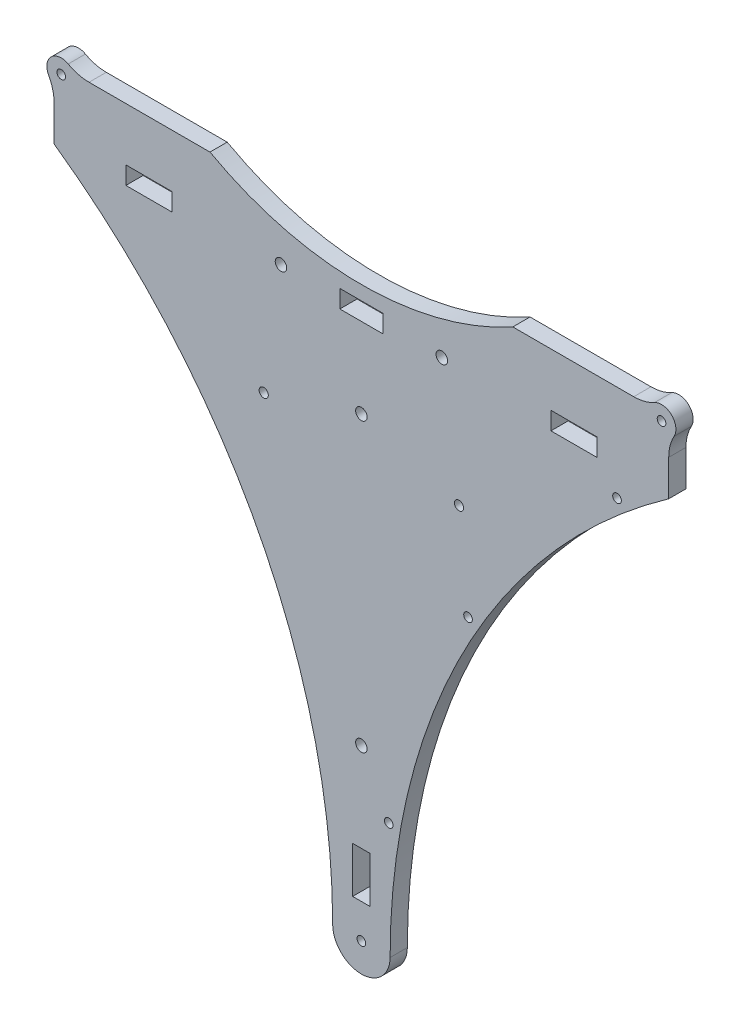
from build123d import *

# Parameters (mm, degrees)
SKETCH1_R           = 1.5
SKETCH1_R_2         = 2
SKETCH1_R_3         = 1.6
SKETCH1_W           = 16
SKETCH1_H           = 6.2
SKETCH1_W_2         = 6.1
SKETCH1_H_2         = 16
SKETCH1_W_3         = 15
BOSS_EXTRUDE1_DEPTH = 6
SKETCH2_R           = 1.5
CUT_EXTRUDE1_DEPTH  = 7


with BuildPart() as part:
    # Sketch1 → Boss-Extrude1 (new body)
    with BuildSketch(Plane.XY):
        with BuildLine():
            Line((86.201143473, 107), (94.817541634, 107))
            ThreePointArc((94.817541634, 107), (98.567541634, 107.476312452), (102.079385409, 108.875))
            ThreePointArc((102.079385409, 108.875), (108.035533906, 108.035533906), (108.875, 102.079385409))
            ThreePointArc((108.875, 102.079385409), (107.476312452, 98.567541634), (107, 94.817541634))
            Line((107, 94.817541634), (107, 82.3))
            ThreePointArc((107, 82.3), (35.695621125, 0.741674255), (10, -104.5))
            ThreePointArc((10, -104.5), (0, -114.5), (-10, -104.5))
            ThreePointArc((-10, -104.5), (-35.695621125, 0.741674255), (-107, 82.3))
            Line((-107, 82.3), (-107, 94.817541634))
            ThreePointArc((-107, 94.817541634), (-107.476312452, 98.567541634), (-108.875, 102.079385409))
            ThreePointArc((-108.875, 102.079385409), (-108.035533906, 108.035533906), (-102.079385409, 108.875))
            ThreePointArc((-102.079385409, 108.875), (-98.567541634, 107.476312452), (-94.817541634, 107))
            Line((-94.817541634, 107), (-91.798856527, 107))
            Line((-91.798856527, 107), (-52.717063467, 107))
            ThreePointArc((-52.717063467, 107), (0, 93.4), (52.717063467, 107))
            Line((52.717063467, 107), (86.201143473, 107))
        make_face()
        with Locations((-104.5, 104.5)):
            Circle(SKETCH1_R, mode=Mode.SUBTRACT)
        with Locations((104.5, 104.5)):
            Circle(SKETCH1_R, mode=Mode.SUBTRACT)
        with Locations((-28, 85.4)):
            Circle(SKETCH1_R_2, mode=Mode.SUBTRACT)
        with Locations((-34, 43.8)):
            Circle(SKETCH1_R_3, mode=Mode.SUBTRACT)
        with Locations((0, 54.4)):
            Circle(SKETCH1_R_2, mode=Mode.SUBTRACT)
        with Locations((0, -104.5)):
            Circle(SKETCH1_R, mode=Mode.SUBTRACT)
        with Locations((0, -45.6)):
            Circle(SKETCH1_R_2, mode=Mode.SUBTRACT)
        with Locations((28, 85.4)):
            Circle(SKETCH1_R_2, mode=Mode.SUBTRACT)
        with Locations((34, 43.8)):
            Circle(SKETCH1_R_3, mode=Mode.SUBTRACT)
        with Locations((-74, 85.4)):
            Rectangle(SKETCH1_W, SKETCH1_H, mode=Mode.SUBTRACT)
        with Locations((74, 85.4)):
            Rectangle(SKETCH1_W, SKETCH1_H, mode=Mode.SUBTRACT)
        with Locations((0, -84.6)):
            Rectangle(SKETCH1_W_2, SKETCH1_H_2, mode=Mode.SUBTRACT)
        with Locations((0, 85.4)):
            Rectangle(SKETCH1_W_3, SKETCH1_H, mode=Mode.SUBTRACT)
    extrude(amount=BOSS_EXTRUDE1_DEPTH)

    # Sketch2 → Cut-Extrude1 (cut, through all)
    with BuildSketch(Plane.XY.offset(6)):
        with Locations((9.530180145, -64.149856306)):
            Circle(SKETCH2_R)
        with Locations((37.131304004, 11.683608247)):
            Circle(SKETCH2_R)
        with Locations((89.004448835, 73.503614959)):
            Circle(SKETCH2_R)
    extrude(amount=-CUT_EXTRUDE1_DEPTH, mode=Mode.SUBTRACT)


solid = part.part
